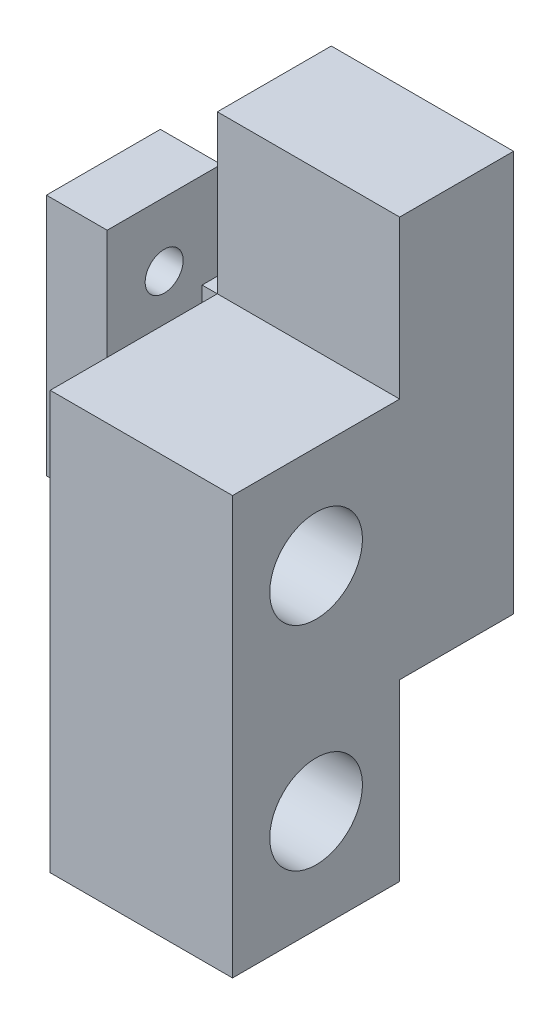
from build123d import *

# Parameters (mm, degrees)
SKETCH1_R           = 3.1
SKETCH1_R_2         = 2.5
BOSS_EXTRUDE1_DEPTH = 15
SKETCH6_R           = 3.1
BOSS_EXTRUDE3_DEPTH = 5
BOSS_EXTRUDE4_DEPTH = 15
SKETCH8_R           = 2.5
CUT_EXTRUDE3_DEPTH  = 25
CUT_EXTRUDE4_DEPTH  = 16
SKETCH11_W          = 24
SKETCH11_H          = 0.25
BOSS_EXTRUDE5_DEPTH = 15
SKETCH12_W          = 24
SKETCH12_H          = 32
SKETCH12_H_2        = 23
BOSS_EXTRUDE6_DEPTH = 22
SKETCH13_R          = 6.1
CUT_EXTRUDE5_DEPTH  = 25


with BuildPart() as part:
    # Sketch1 → Boss-Extrude1 (new body)
    with BuildSketch(Plane.XY):
        with BuildLine():
            Line((-25.80048806, 37.524276553), (-49.80048806, 37.524276553))
            Line((-49.80048806, 37.524276553), (-49.80048806, -14.975723447))
            Line((-49.80048806, -14.975723447), (-41.80048806, -45.286414829))
            ThreePointArc((-41.80048806, -45.286414829), (-37.80048806, -49.286414829), (-33.80048806, -45.286414829))
            Line((-33.80048806, -45.286414829), (-25.80048806, -14.975723447))
            Line((-25.80048806, -14.975723447), (-25.80048806, 37.524276553))
        make_face()
        with Locations((-37.80048806, 25.524276553)):
            Circle(SKETCH1_R, mode=Mode.SUBTRACT)
        with Locations((-37.80048806, -2.975723447)):
            Circle(SKETCH1_R, mode=Mode.SUBTRACT)
        with Locations((-37.80048806, -45.286414829)):
            Circle(SKETCH1_R_2, mode=Mode.SUBTRACT)
    extrude(amount=BOSS_EXTRUDE1_DEPTH)

    # Sketch6 → Boss-Extrude3 (add)
    with BuildSketch(Plane.XY.offset(15)):
        with Locations((-37.80048806, -2.975723447)):
            Circle(SKETCH6_R)
        with Locations((-37.80048806, 25.524276553)):
            Circle(SKETCH6_R)
    extrude(amount=-BOSS_EXTRUDE3_DEPTH)

    # Sketch7 → Boss-Extrude4 (add)
    with BuildSketch(Plane.XY.offset(15)):
        Polygon((-51.800511672, 16.774276553), (-49.80048806, 16.774276553), (-49.80048806, -15.225723447), (-72.300511672, -15.225723447), (-72.300511672, 16.774276553), (-64.300511672, 16.774276553), (-64.300511672, -7.225723447), (-58.050499866, -7.225723447), (-51.800511672, -7.225723447), align=None)
    extrude(amount=-BOSS_EXTRUDE4_DEPTH)

    # Sketch8 → Cut-Extrude3 (cut)
    with BuildSketch(Plane.ZY.offset(72.300511672)):
        with Locations((7.5, 8.346782821)):
            Circle(SKETCH8_R)
    extrude(amount=-CUT_EXTRUDE3_DEPTH, mode=Mode.SUBTRACT)

    # Sketch10 → Cut-Extrude4 (cut, through all)
    with BuildSketch(Plane.XY.offset(15)):
        Polygon((-49.80048806, -15.225723447), (-49.80048806, -14.975723447), (-25.80048806, -14.975723447), (-25.80048806, -50.615055613), (-49.80048806, -50.615055613), align=None)
    extrude(amount=-CUT_EXTRUDE4_DEPTH, mode=Mode.SUBTRACT)

    # Sketch11 → Boss-Extrude5 (add)
    with BuildSketch(Plane.XY.offset(15)):
        with Locations((-37.80048806, -15.100723447)):
            Rectangle(SKETCH11_W, SKETCH11_H)
    extrude(amount=-BOSS_EXTRUDE5_DEPTH)

    # Sketch12 → Boss-Extrude6 (add)
    with BuildSketch(Plane.XY.offset(15)):
        with Locations((-37.80048806, 0.774276553)):
            Rectangle(SKETCH12_W, SKETCH12_H)
        with Locations((-37.80048806, -26.725723447)):
            Rectangle(SKETCH12_W, SKETCH12_H_2)
    extrude(amount=BOSS_EXTRUDE6_DEPTH)

    # Sketch13 → Cut-Extrude5 (cut, through all)
    with BuildSketch(Plane.ZY.offset(49.80048806)):
        with Locations((26, 3.274276553)):
            Circle(SKETCH13_R)
        with Locations((26, -24.725723447)):
            Circle(SKETCH13_R)
    extrude(amount=-CUT_EXTRUDE5_DEPTH, mode=Mode.SUBTRACT)


solid = part.part
